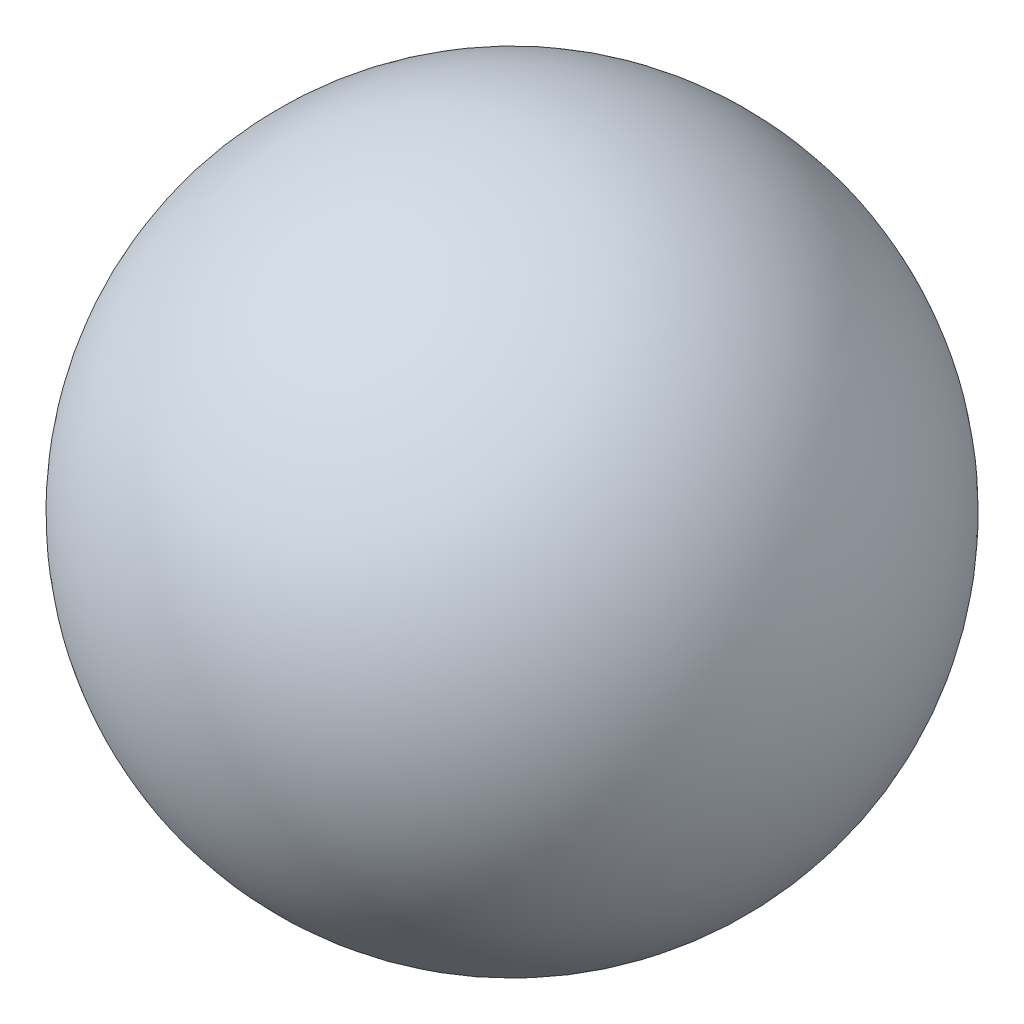
from build123d import *


with BuildPart() as part:
    # Sketch1 → Revolve1 (revolve)
    with BuildSketch(Plane(origin=(0, 0, 0), x_dir=(1, 0, 0), z_dir=(0, 1, 0))):
        with BuildLine():
            Line((0, -0.05), (0, 0.05))
            ThreePointArc((0, 0.05), (0.05, 0), (0, -0.05))
        make_face()
    revolve(axis=Axis((0, 0, 0.05), (0, 0, -1)))


solid = part.part
